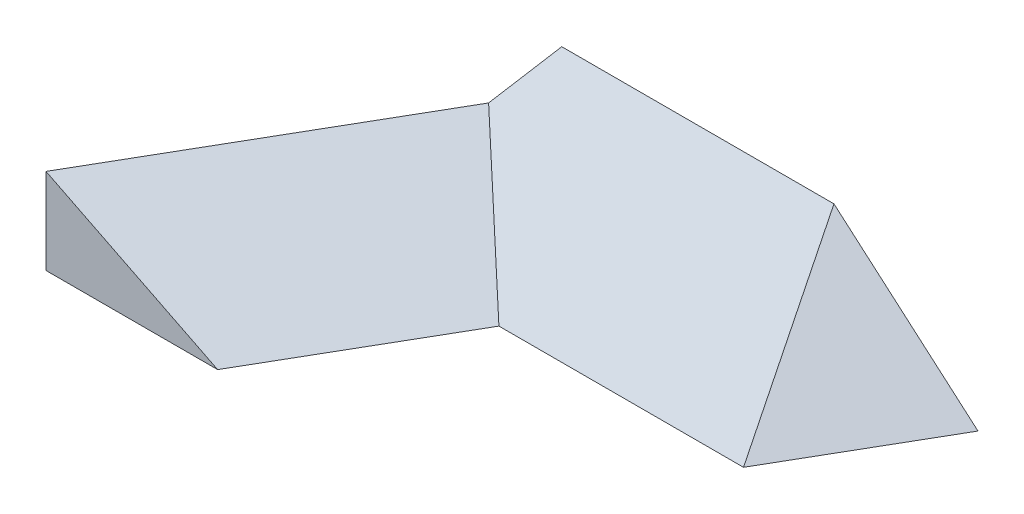
from build123d import *

# Parameters (mm, degrees)
EXTRUDE1_DEPTH          = 153.73
EXTRUDE2_DEPTH          = 127.02
CUT_EXTRUDE1_DEPTH      = 42.954981559
CUT_EXTRUDE2_DEPTH      = 40
CUT_EXTRUDE2_DEPTH_BACK = 60
SKETCH10_W              = 60.093449
SKETCH10_H              = 28.719359
CUT_EXTRUDE3_DEPTH      = 42.954981559


with BuildPart() as part:
    # Sketch1 → Extrude1 (new body)
    with BuildSketch(Plane(origin=(0, 0, 0), x_dir=(0, 0, -1), z_dir=(1, 0, 0))):
        Polygon((0, 0), (0, 41.954981559), (-50, 0), align=None)
    extrude(amount=-EXTRUDE1_DEPTH)

    # Sketch4 → Extrude2 (add)
    with BuildSketch(Plane(origin=(-98.508529611, 0, 170.621778265), x_dir=(0.866025404, 0, 0.5), z_dir=(-0.5, 0, 0.866025404))):
        Polygon((-121.243556529, 28.867513459), (-71.243556529, 0), (-121.243556529, 0), align=None)
    extrude(amount=-EXTRUDE2_DEPTH)

    # Sketch6 → Cut-Extrude1 (cut, through all)
    with BuildSketch(Plane(origin=(0, 0, 0), x_dir=(1, 0, 0), z_dir=(0, 1, 0))):
        Polygon((-161.048753394, -36.457510316), (-140, 0), (-161.048753394, 0), align=None)
    extrude(amount=CUT_EXTRUDE1_DEPTH, mode=Mode.SUBTRACT)

    # Sketch9 → Cut-Extrude2 (cut, two sides)
    with BuildSketch(Plane(origin=(-28.867513459, 0, 50), x_dir=(0.866025404, 0, 0.5), z_dir=(-0.5, 0, 0.866025404))) as cut_extrude2_sk:
        Polygon((33.293903828, 48.675552454), (33.293903828, 0), (0, 0), (-48.675552454, 48.675552454), align=None)
    extrude(amount=CUT_EXTRUDE2_DEPTH, mode=Mode.SUBTRACT)
    extrude(cut_extrude2_sk.sketch, amount=-CUT_EXTRUDE2_DEPTH_BACK, mode=Mode.SUBTRACT)

    # Sketch10 → Cut-Extrude3 (cut, through all)
    with BuildSketch(Plane(origin=(0, 0, 0), x_dir=(1, 0, 0), z_dir=(0, 1, 0))):
        with Locations((-173.7940015, -124.3340965)):
            Rectangle(SKETCH10_W, SKETCH10_H)
    extrude(amount=CUT_EXTRUDE3_DEPTH, mode=Mode.SUBTRACT)


solid = part.part
